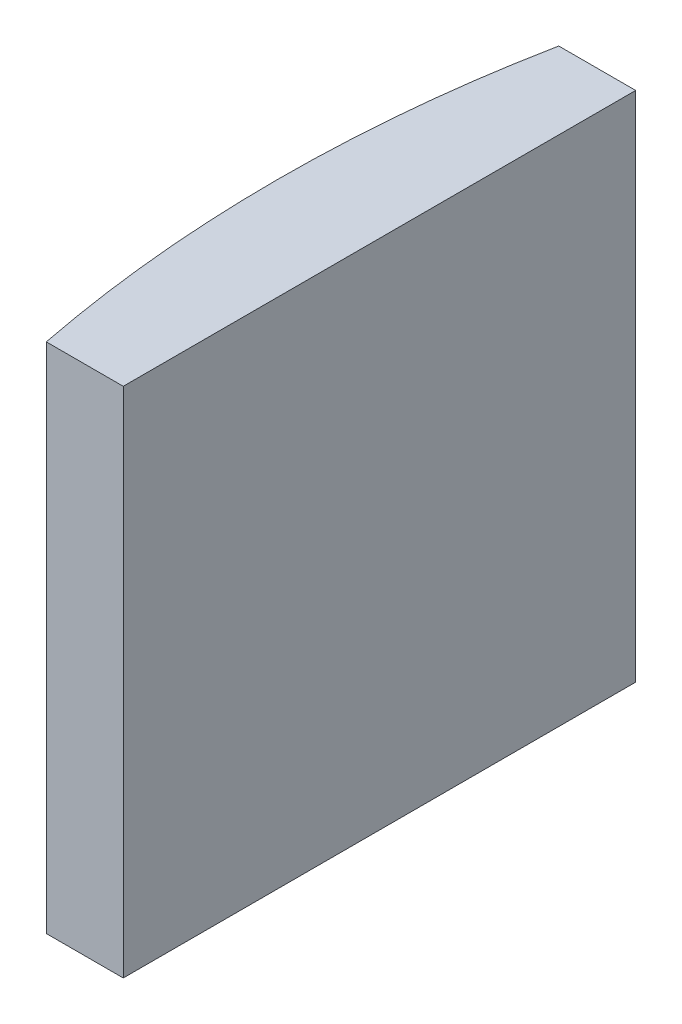
from build123d import *

# Parameters (mm, degrees)
EXTRUDE_1_DEPTH = 20


with BuildPart() as part:
    # 草图1 → 凸台-拉伸1 (new body)
    with BuildSketch(Plane(origin=(0, 0, 0), x_dir=(1, 0, 0), z_dir=(0, 1, 0))):
        with BuildLine():
            Line((-46.348073666, 10), (-43.344795665, 10))
            Line((-43.344795665, 10), (-43.344795665, -10))
            Line((-43.344795665, -10), (-46.348073666, -10))
            ThreePointArc((-46.348073666, -10), (-47.324795665, 0), (-46.348073666, 10))
        make_face()
    extrude(amount=EXTRUDE_1_DEPTH)


solid = part.part
